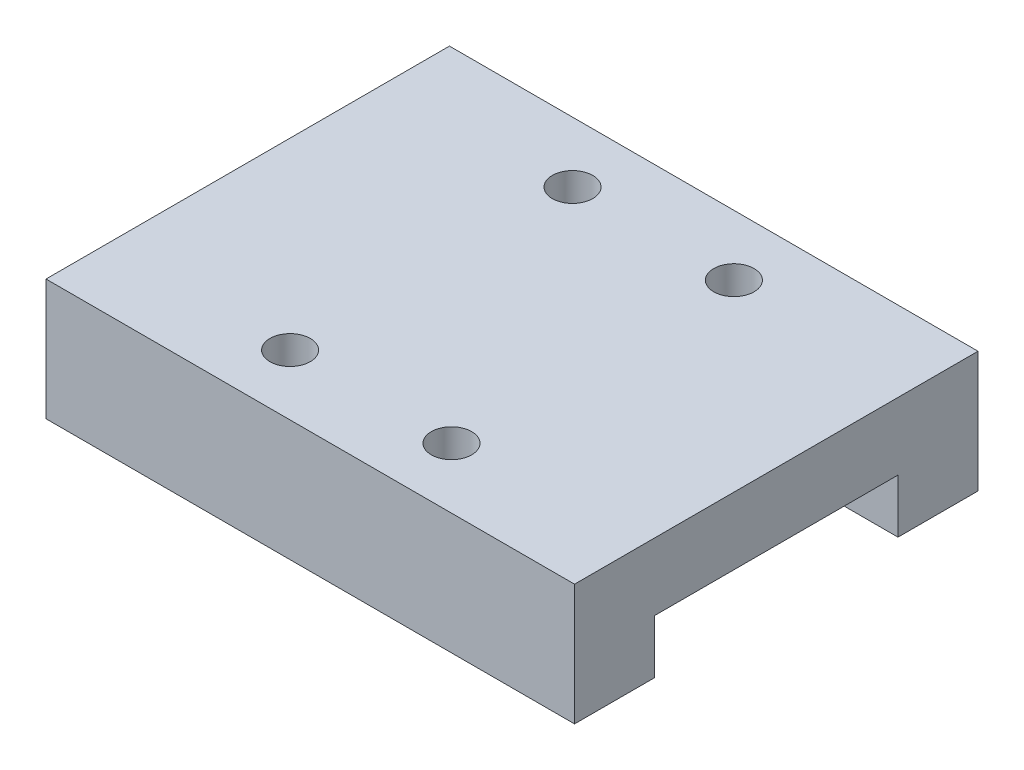
from build123d import *

# Parameters (mm, degrees)
SKETCH_1_W          = 39.3
SKETCH_1_H          = 30
EXTRUDE_1_DEPTH     = 9
SKETCH_2_W          = 39.3
SKETCH_2_H          = 18.1
CUT_EXTRUDE_1_DEPTH = 4
SKETCH_3_R          = 1.5
CUT_EXTRUDE_2_DEPTH = 5


with BuildPart() as part:
    # 草图1 → 凸台-拉伸1 (new body)
    with BuildSketch(Plane(origin=(0, 0, 0), x_dir=(1, 0, 0), z_dir=(0, 1, 0))):
        Rectangle(SKETCH_1_W, SKETCH_1_H)
    extrude(amount=EXTRUDE_1_DEPTH)

    # 草图2 → 切除-拉伸1 (cut)
    with BuildSketch(Plane.XZ):
        Rectangle(SKETCH_2_W, SKETCH_2_H)
    extrude(amount=-CUT_EXTRUDE_1_DEPTH, mode=Mode.SUBTRACT)

    # 草图3 → 切除-拉伸2 (cut)
    with BuildSketch(Plane(origin=(0, 9, 0), x_dir=(1, 0, 0), z_dir=(0, 1, 0))):
        with Locations((-6, 10.5)):
            Circle(SKETCH_3_R)
        with Locations((6, 10.5)):
            Circle(SKETCH_3_R)
        with Locations((6, -10.5)):
            Circle(SKETCH_3_R)
        with Locations((-6, -10.5)):
            Circle(SKETCH_3_R)
    extrude(amount=-CUT_EXTRUDE_2_DEPTH, mode=Mode.SUBTRACT)


solid = part.part
